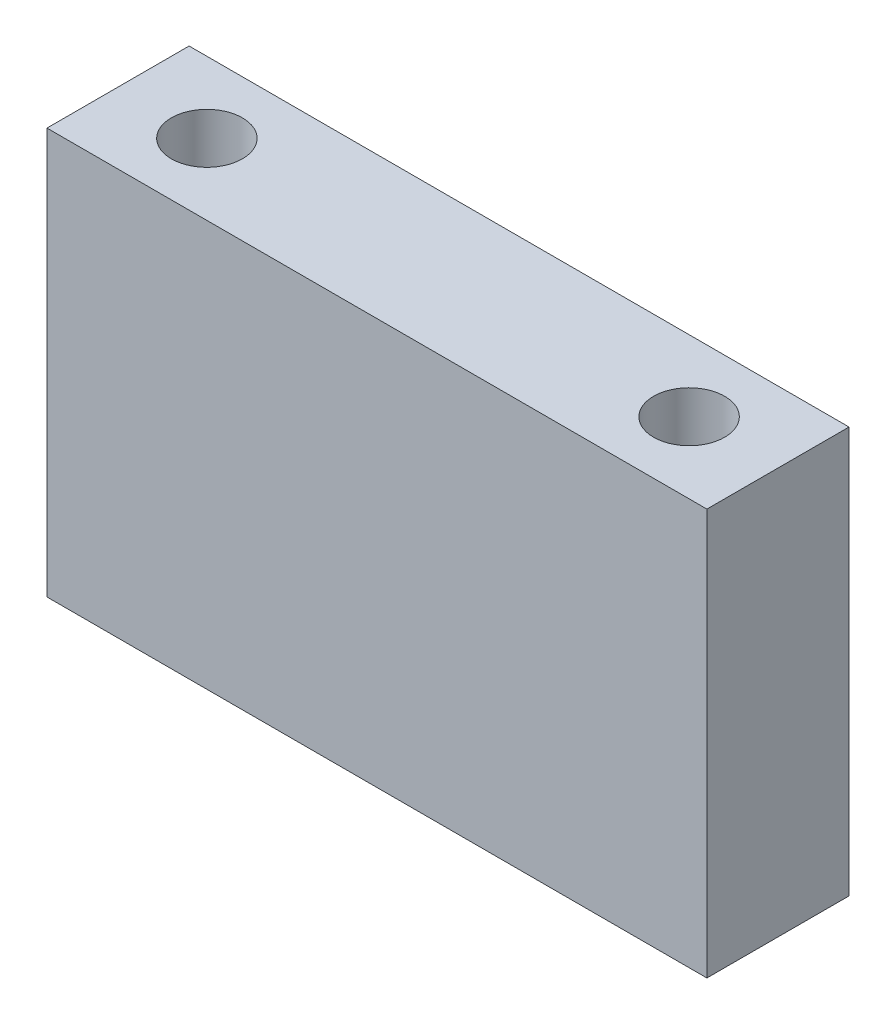
from build123d import *

# Parameters (mm, degrees)
SKETCH1_W      = 65
SKETCH1_H      = 40
EXTRUDE1_DEPTH = 14
SKETCH2_R      = 3.5
EXTRUDE2_DEPTH = 41


with BuildPart() as part:
    # Sketch1 → Extrude1 (new body)
    with BuildSketch(Plane.XY):
        with Locations((32.5, 20)):
            Rectangle(SKETCH1_W, SKETCH1_H)
    extrude(amount=EXTRUDE1_DEPTH)

    # Sketch2 → Extrude2 (cut, through all)
    with BuildSketch(Plane(origin=(0, 40, 0), x_dir=(1, 0, 0), z_dir=(0, 1, 0))):
        with Locations(Location((8.75, -7, 0), (0, 0, 270))):  # turned: the seam where the file's is
            Circle(SKETCH2_R)
        with Locations(Location((56.25, -7, 0), (0, 0, 270))):  # turned: the seam where the file's is
            Circle(SKETCH2_R)
    extrude(amount=-EXTRUDE2_DEPTH, mode=Mode.SUBTRACT)


solid = part.part
